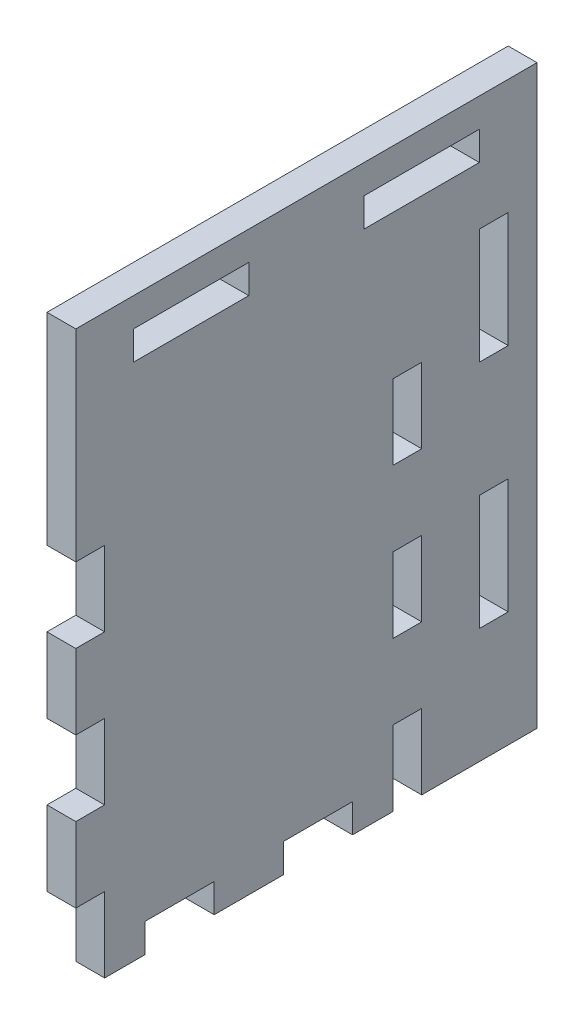
from build123d import *

# Parameters (mm, degrees)
BOSS_EXTRU_1_DEPTH         = 5
ESQUISSE2_W                = 12
ESQUISSE2_H                = 5
ENL_V_MAT_EXTRU_1_DEPTH    = 5
R_P_TITION_LIN_AIRE1_COUNT = 2
R_P_TITION_LIN_AIRE1_PITCH = 24
ESQUISSE4_W                = 5
ESQUISSE4_H                = 13
ENL_V_MAT_EXTRU_2_DEPTH    = 5
R_P_TITION_LIN_AIRE2_COUNT = 3
R_P_TITION_LIN_AIRE2_PITCH = 26
SYM_TRIE1_COPY_1_SKETCH_W  = 5
SYM_TRIE1_COPY_1_SKETCH_H  = 13
SYM_TRIE1_COPY_1_DEPTH     = 5
SYM_TRIE1_COPY_2_SKETCH_W  = 5
SYM_TRIE1_COPY_2_SKETCH_H  = 13
SYM_TRIE1_COPY_2_DEPTH     = 5
BOSS_EXTRU_3_DEPTH         = 5
ESQUISSE7_W                = 20
ESQUISSE7_H                = 5
ENL_V_MAT_EXTRU_3_DEPTH    = 5
ESQUISSE8_W                = 5
ESQUISSE8_H                = 20
ENL_V_MAT_EXTRU_4_DEPTH    = 5


with BuildPart() as part:
    # Esquisse1 → Boss.-Extru.1 (new body)
    with BuildSketch(Plane(origin=(0, 0, 0), x_dir=(0, 0, -1), z_dir=(1, 0, 0))):
        Polygon((0, 0), (0, 35), (45, 35), (45, 0), (60, 0), (60, -65), (0, -65), align=None)
    extrude(amount=BOSS_EXTRU_1_DEPTH)

    # Esquisse2 → Enlèv. mat.-Extru.1 (cut)
    with BuildSketch(Plane(origin=(5, 0, 0), x_dir=(0, 0, -1), z_dir=(1, 0, 0))):
        with Locations((18, -62.5)):
            Rectangle(ESQUISSE2_W, ESQUISSE2_H)
    enl_v_mat_extru_1 = extrude(amount=-ENL_V_MAT_EXTRU_1_DEPTH, mode=Mode.SUBTRACT)

    # Répétition linéaire1: Enlèv. mat.-Extru.1 ×2
    with Locations(*[(0, 0, -i * R_P_TITION_LIN_AIRE1_PITCH) for i in range(1, R_P_TITION_LIN_AIRE1_COUNT)]):
        add(enl_v_mat_extru_1, mode=Mode.SUBTRACT)

    # Esquisse4 → Enlèv. mat.-Extru.2 (cut)
    with BuildSketch(Plane(origin=(5, 0, 0), x_dir=(0, 0, -1), z_dir=(1, 0, 0))):
        with Locations((2.5, -58.5)):
            Rectangle(ESQUISSE4_W, ESQUISSE4_H)
    enl_v_mat_extru_2 = extrude(amount=-ENL_V_MAT_EXTRU_2_DEPTH, mode=Mode.SUBTRACT)

    # Répétition linéaire2: Enlèv. mat.-Extru.2 ×3
    with Locations(*[(0, i * R_P_TITION_LIN_AIRE2_PITCH, 0) for i in range(1, R_P_TITION_LIN_AIRE2_COUNT)]):
        add(enl_v_mat_extru_2, mode=Mode.SUBTRACT)

    # Symétrie1: Enlèv. mat.-Extru.2 across plane
    add(enl_v_mat_extru_2.mirror(Plane.XY.offset(-30)), mode=Mode.SUBTRACT)

    # Symétrie1 copy 1 sketch → Symétrie1 copy 1 (cut)
    with BuildSketch(Plane(origin=(5, 26, -60), x_dir=(0, 0, 1), z_dir=(1, 0, 0))):
        with Locations((2.5, 58.5)):
            Rectangle(SYM_TRIE1_COPY_1_SKETCH_W, SYM_TRIE1_COPY_1_SKETCH_H)
    extrude(amount=-SYM_TRIE1_COPY_1_DEPTH, mode=Mode.SUBTRACT)

    # Symétrie1 copy 2 sketch → Symétrie1 copy 2 (cut)
    with BuildSketch(Plane(origin=(5, 52, -60), x_dir=(0, 0, 1), z_dir=(1, 0, 0))):
        with Locations((2.5, 58.5)):
            Rectangle(SYM_TRIE1_COPY_2_SKETCH_W, SYM_TRIE1_COPY_2_SKETCH_H)
    extrude(amount=-SYM_TRIE1_COPY_2_DEPTH, mode=Mode.SUBTRACT)

    # Esquisse5 → Boss.-Extru.3 (add)
    with BuildSketch(Plane(origin=(5, 0, 0), x_dir=(0, 0, -1), z_dir=(1, 0, 0))):
        Polygon((45, 0), (60, 0), (60, -65), (80, -65), (80, 35), (45, 35), align=None)
    extrude(amount=-BOSS_EXTRU_3_DEPTH)

    # Esquisse7 → Enlèv. mat.-Extru.3 (cut)
    with BuildSketch(Plane(origin=(5, 0, 0), x_dir=(0, 0, -1), z_dir=(1, 0, 0))):
        with Locations((20, 27.5)):
            Rectangle(ESQUISSE7_W, ESQUISSE7_H)
        with Locations((60, 27.5)):
            Rectangle(ESQUISSE7_W, ESQUISSE7_H)
    extrude(amount=-ENL_V_MAT_EXTRU_3_DEPTH, mode=Mode.SUBTRACT)

    # Esquisse8 → Enlèv. mat.-Extru.4 (cut)
    with BuildSketch(Plane(origin=(5, 0, 0), x_dir=(0, 0, -1), z_dir=(1, 0, 0))):
        with Locations((72.5, 5)):
            Rectangle(ESQUISSE8_W, ESQUISSE8_H)
        with Locations((72.5, -35)):
            Rectangle(ESQUISSE8_W, ESQUISSE8_H)
    extrude(amount=-ENL_V_MAT_EXTRU_4_DEPTH, mode=Mode.SUBTRACT)


solid = part.part
